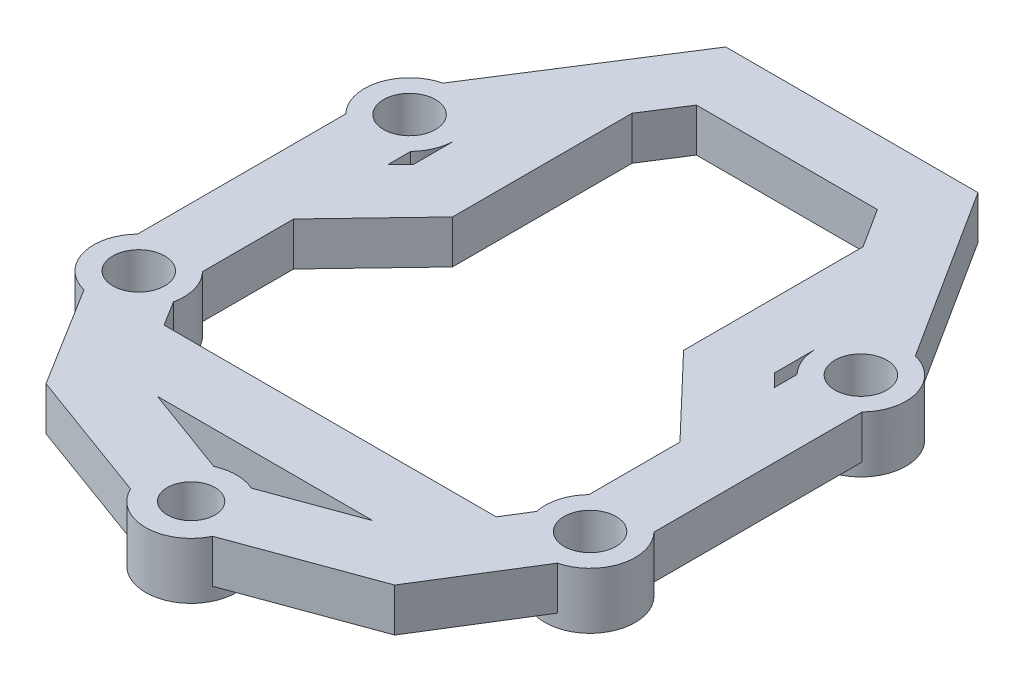
from build123d import *

# Parameters (mm, degrees)
SKETCH1_R           = 1.2
SKETCH1_R_2         = 1.1
BOSS_EXTRUDE1_DEPTH = 2
BOSS_EXTRUDE2_START = -0.6
SKETCH2_4_R         = 1.2
SKETCH2_4_R_2       = 2.083333333
SKETCH2_4_R_3       = 2.1
SKETCH2_4_R_4       = 1.1
BOSS_EXTRUDE2_DEPTH = 0.6


with BuildPart() as part:
    # Sketch1 → Boss-Extrude1 (new body)
    with BuildSketch(Plane(origin=(0, 0, 0), x_dir=(1, 0, 0), z_dir=(0, 1, 0))):
        with BuildLine():
            Line((-5.822800045, 12.5), (-10.904671205, 4.52537141))
            ThreePointArc((-10.904671205, 4.52537141), (-12.416732246, 3.083108444), (-11.916666667, 1.054220702))
            Line((-11.916666667, 1.054220702), (-11.916666667, -8.554220702))
            ThreePointArc((-11.916666667, -8.554220702), (-12.419965446, -10.571901894), (-10.927318432, -12.019780323))
            Line((-10.927318432, -12.019780323), (-8.048319684, -16.65121309))
            Line((-8.048319684, -16.65121309), (-1.895755615, -18.903388425))
            ThreePointArc((-1.895755615, -18.903388425), (0, -20.1), (1.895755615, -18.903388425))
            Line((1.895755615, -18.903388425), (8.048319684, -16.65121309))
            Line((8.048319684, -16.65121309), (10.927318432, -12.019780323))
            ThreePointArc((10.927318432, -12.019780323), (12.419965446, -10.571901894), (11.916666667, -8.554220702))
            Line((11.916666667, -8.554220702), (11.916666667, 1.054220702))
            ThreePointArc((11.916666667, 1.054220702), (12.416732246, 3.083108444), (10.904671205, 4.52537141))
            Line((10.904671205, 4.52537141), (5.822800045, 12.5))
            Line((5.822800045, 12.5), (-5.822800045, 12.5))
        make_face()
        with BuildLine():
            Line((-8.333333333, 0.601446463), (-8.916666667, -0.009018653))
            Line((-8.916666667, -0.009018653), (-8.916666667, 1.054220702))
            ThreePointArc((-8.916666667, 1.054220702), (-8.484662813, 1.720488044), (-8.333333333, 2.5))
            Line((-8.333333333, 2.5), (-8.333333333, 0.601446463))
        make_face(mode=Mode.SUBTRACT)
        with BuildLine():
            Line((8.333333333, 0.601446463), (8.333333333, 2.5))
            ThreePointArc((8.333333333, 2.5), (8.484662813, 1.720488044), (8.916666667, 1.054220702))
            Line((8.916666667, 1.054220702), (8.916666667, 0))
            Line((8.916666667, 0), (8.333333333, 0.601446463))
        make_face(mode=Mode.SUBTRACT)
        with BuildLine():
            Line((5.333333333, -0.601446463), (8.916666667, -4.351446463))
            Line((8.916666667, -4.351446463), (8.916666667, -8.554220702))
            ThreePointArc((8.916666667, -8.554220702), (8.413367887, -9.428098106), (8.379462456, -10.435977959))
            Line((8.379462456, -10.435977959), (7.666241548, -11.583333333))
            Line((7.666241548, -11.583333333), (-7.666241548, -11.583333333))
            Line((-7.666241548, -11.583333333), (-8.379462456, -10.435977959))
            ThreePointArc((-8.379462456, -10.435977959), (-8.413367887, -9.428098106), (-8.916666667, -8.554220702))
            Line((-8.916666667, -8.554220702), (-8.916666667, -4.351446463))
            Line((-8.916666667, -4.351446463), (-5.333333333, -0.601446463))
            Line((-5.333333333, -0.601446463), (-5.333333333, 7.685759929))
            Line((-5.333333333, 7.685759929), (-4.177199955, 9.5))
            Line((-4.177199955, 9.5), (4.177199955, 9.5))
            Line((4.177199955, 9.5), (5.333333333, 7.685759929))
            Line((5.333333333, 7.685759929), (5.333333333, -0.601446463))
        make_face(mode=Mode.SUBTRACT)
        with Locations((-10.416666667, 2.5)):
            Circle(SKETCH1_R, mode=Mode.SUBTRACT)
        with Locations((10.416666667, 2.5)):
            Circle(SKETCH1_R, mode=Mode.SUBTRACT)
        with Locations((-10.416666667, -10)):
            Circle(SKETCH1_R, mode=Mode.SUBTRACT)
        with Locations((10.416666667, -10)):
            Circle(SKETCH1_R, mode=Mode.SUBTRACT)
        with BuildLine():
            Line((-4.970097661, -14.583333333), (4.970097661, -14.583333333))
            Line((4.970097661, -14.583333333), (0.864511388, -16.086202712))
            ThreePointArc((0.864511388, -16.086202712), (0, -15.9), (-0.864511388, -16.086202712))
            Line((-0.864511388, -16.086202712), (-4.970097661, -14.583333333))
        make_face(mode=Mode.SUBTRACT)
        with Locations((0, -18)):
            Circle(SKETCH1_R_2, mode=Mode.SUBTRACT)
    extrude(amount=BOSS_EXTRUDE1_DEPTH)

    # Sketch2_4 → Boss-Extrude2 (add)
    # profile 1 of 5: a face of its own
    with BuildSketch(Plane(origin=(0, 0, 0), x_dir=(1, 0, 0), z_dir=(0, 1, 0)).offset(BOSS_EXTRUDE2_START)):
        with BuildLine():
            ThreePointArc((-10.927318432, -12.019780323), (-8.614659909, -11.04549004), (-8.916666667, -8.554220702))
            ThreePointArc((-8.916666667, -8.554220702), (-12.218673424, -8.95450996), (-10.927318432, -12.019780323))
        make_face()
        with Locations((-10.416666667, -10)):
            Circle(SKETCH2_4_R, mode=Mode.SUBTRACT)
    # profile 2 of 5: a face of its own
    with BuildSketch(Plane(origin=(0, 0, 0), x_dir=(1, 0, 0), z_dir=(0, 1, 0)).offset(BOSS_EXTRUDE2_START)):
        with Locations((-10.416666667, 2.5)):
            Circle(SKETCH2_4_R_2)
        with Locations((-10.416666667, 2.5)):
            Circle(SKETCH2_4_R, mode=Mode.SUBTRACT)
    # profile 3 of 5: a face of its own
    with BuildSketch(Plane(origin=(0, 0, 0), x_dir=(1, 0, 0), z_dir=(0, 1, 0)).offset(BOSS_EXTRUDE2_START)):
        with BuildLine():
            ThreePointArc((8.916666667, -8.554220702), (8.614659909, -11.04549004), (10.927318432, -12.019780323))
            ThreePointArc((10.927318432, -12.019780323), (12.218673424, -8.95450996), (8.916666667, -8.554220702))
        make_face()
        with Locations((10.416666667, -10)):
            Circle(SKETCH2_4_R, mode=Mode.SUBTRACT)
    # profile 4 of 5: a face of its own
    with BuildSketch(Plane(origin=(0, 0, 0), x_dir=(1, 0, 0), z_dir=(0, 1, 0)).offset(BOSS_EXTRUDE2_START)):
        with Locations((0, -18)):
            Circle(SKETCH2_4_R_3)
        with Locations((0, -18)):
            Circle(SKETCH2_4_R_4, mode=Mode.SUBTRACT)
    # profile 5 of 5: a face of its own
    with BuildSketch(Plane(origin=(0, 0, 0), x_dir=(1, 0, 0), z_dir=(0, 1, 0)).offset(BOSS_EXTRUDE2_START)):
        with Locations((10.416666667, 2.5)):
            Circle(SKETCH2_4_R_2)
        with Locations((10.416666667, 2.5)):
            Circle(SKETCH2_4_R, mode=Mode.SUBTRACT)
    extrude(amount=BOSS_EXTRUDE2_DEPTH)


solid = part.part
